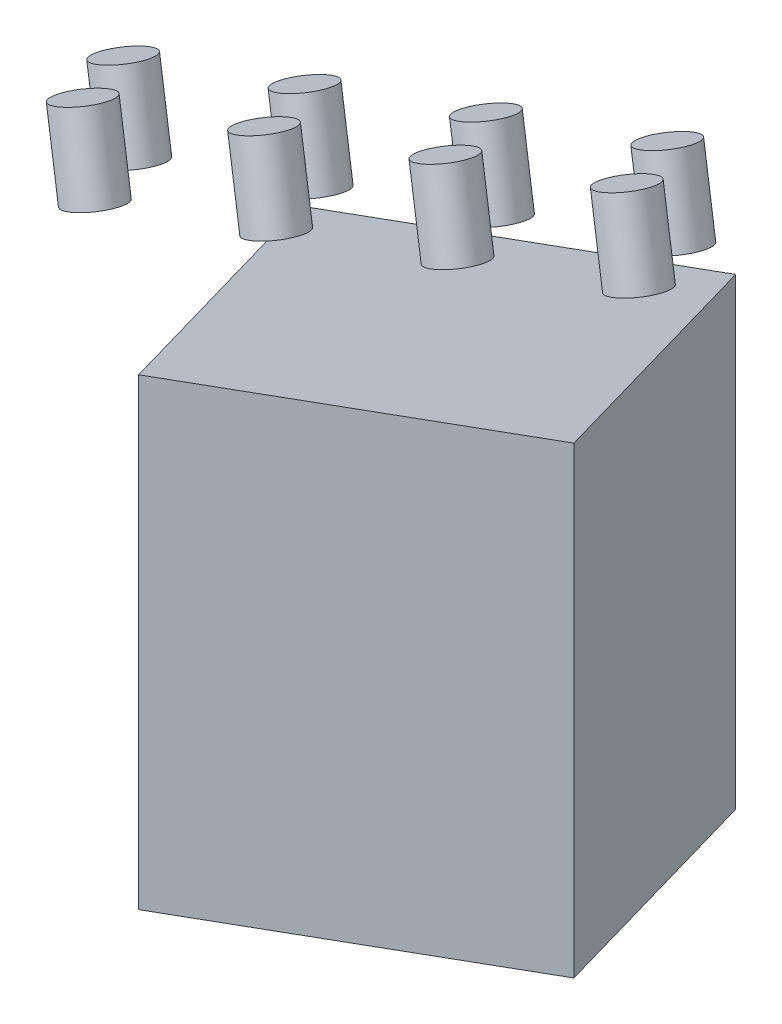
from build123d import *

# Parameters (mm, degrees)
SKIZZE1_R                       = 3.358360703
AUFSATZ_LINEAR_AUSTRAGEN1_DEPTH = 10
LINEARES_MUSTER2_COUNT          = 4
LINEARES_MUSTER2_PITCH          = 25
LINEARES_MUSTER2_COUNT_DIR2     = 2
LINEARES_MUSTER2_PITCH_DIR2     = 15


with BuildPart() as part:
    # Austragung1: sweep along a path in SK Pfad
    with BuildLine(Plane(origin=(0, 0, 0), x_dir=(0, 0, 1), z_dir=(-0.573576436, 0.819152044, 0))) as austragung1_path:
        Line((0, 0), (49.149122657, 34.414586181))
    # SK Grundriss → Austragung1 (sweep)
    with BuildSketch(Plane.XY):
        Polygon((0, 0), (0, 60), (56.381557247, 80.5212086), (56.381557247, 20.5212086), align=None)
    sweep(path=austragung1_path.line)


with BuildPart() as body_2:
    # Skizze1 → Aufsatz-Linear austragen1 (new body)
    with BuildSketch(Plane(origin=(-18.670430807, 51.296587053, -9.892946648), x_dir=(0.941669784, 0.330449009, -0.063729667), z_dir=(-0.336538286, 0.924631341, -0.178322361))):
        with Locations(Location((74.295440009, -22.475001385, 0), (0, 0, 176.286481511))):  # turned: the seam where the file's is
            Circle(SKIZZE1_R)
    aufsatz_linear_austragen1 = extrude(amount=AUFSATZ_LINEAR_AUSTRAGEN1_DEPTH)


with BuildPart() as lineares_muster2_1:
    # Lineares Muster2: Aufsatz-Linear austragen1 4 × 2
    with Locations(*[Vector(-0.939692621, -0.342020143, 0) * (i * LINEARES_MUSTER2_PITCH) + Vector(-0.46984631, -0.328989928, -0.819152044) * (j * LINEARES_MUSTER2_PITCH_DIR2) for i in range(LINEARES_MUSTER2_COUNT) for j in range(LINEARES_MUSTER2_COUNT_DIR2) if (i, j) != (0, 0)]):
        add(aufsatz_linear_austragen1)


solid = Compound([part.part, body_2.part, lineares_muster2_1.part])
